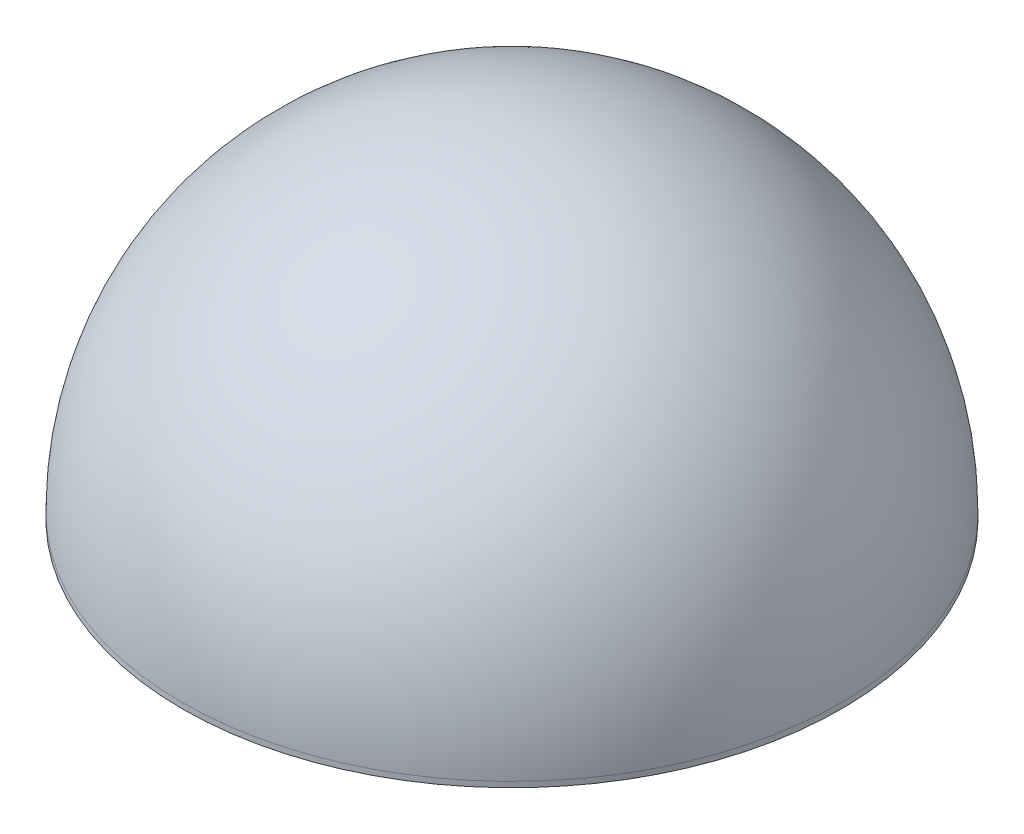
from build123d import *

# Parameters (mm, degrees)
SKETCH1_R           = 152.4
BOSS_EXTRUDE1_DEPTH = 2.54
DOME1_FACE_RADIUS   = 152.4
DOME1_HEIGHT        = 152.4


with BuildPart() as part:
    # Sketch1 → Boss-Extrude1 (new body)
    with BuildSketch(Plane(origin=(0, 0, 0), x_dir=(1, 0, 0), z_dir=(0, 1, 0))):
        Circle(SKETCH1_R)
    extrude(amount=BOSS_EXTRUDE1_DEPTH)

    # Dome1: a dome of height H over a round flat face of radius A is a cap of a sphere of radius (A * A + H * H) / (2 * H)
    dome1_r = (DOME1_FACE_RADIUS * DOME1_FACE_RADIUS + DOME1_HEIGHT * DOME1_HEIGHT) / (2 * DOME1_HEIGHT)
    dome1_base = Plane((0, 2.54, 0), z_dir=(0, 1, 0))
    with Locations(dome1_base.offset(DOME1_HEIGHT - dome1_r)):
        dome1_ball = Sphere(dome1_r, mode=Mode.PRIVATE)
    add(split(dome1_ball, bisect_by=dome1_base, keep=Keep.TOP, mode=Mode.PRIVATE))


solid = part.part
